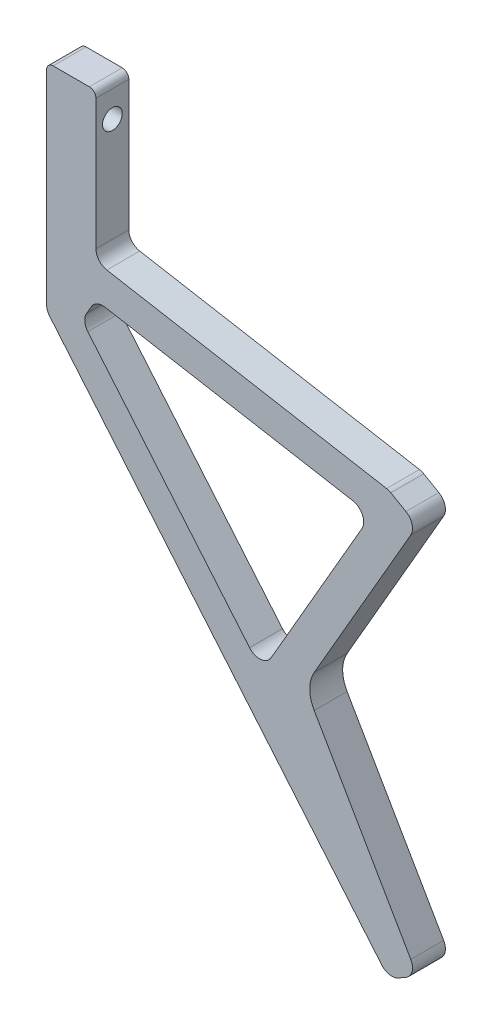
from build123d import *

# Parameters (mm, degrees)
BOSS_EXTRUDE1_DEPTH = 3.175
SKETCH2_R           = 1.905
CUT_EXTRUDE1_DEPTH  = 9.525
CUT_EXTRUDE2_DEPTH  = 6.35
FILLET1_R           = 2.54
FILLET2_R           = 1.27


with BuildPart() as part:
    # Sketch1 → Boss-Extrude1 (new body, symmetric)
    with BuildSketch(Plane.XY):
        with BuildLine():
            Line((-5.499261314, 3.175), (14.408622788, 37.656466735))
            Line((14.408622788, 37.656466735), (8.909361473, 40.831466735))
            Line((8.909361473, 40.831466735), (-47.625, 50.8))
            Line((-47.625, 50.8), (-47.625, 79.375))
            Line((-47.625, 79.375), (-57.15, 79.375))
            Line((-57.15, 79.375), (-57.15, 37.895014625))
            Line((-57.15, 37.895014625), (8.909361473, -40.831466735))
            Line((8.909361473, -40.831466735), (14.408622788, -37.656466735))
            Line((14.408622788, -37.656466735), (-5.499261314, -3.175))
            ThreePointArc((-5.499261314, -3.175), (-6.35, 0), (-5.499261314, 3.175))
        make_face()
    extrude(amount=BOSS_EXTRUDE1_DEPTH, both=True)

    # Sketch2 → Cut-Extrude1 (cut)
    with BuildSketch(Plane(origin=(-47.625, 0, 0), x_dir=(0, 0, -1), z_dir=(1, 0, 0))):
        with Locations((0, 73.025)):
            Circle(SKETCH2_R)
    extrude(amount=-CUT_EXTRUDE1_DEPTH, mode=Mode.SUBTRACT)

    # Sketch3 → Cut-Extrude2 (cut)
    with BuildSketch(Plane.XY.offset(3.175)):
        Polygon((-47.625, 44.352041015), (-50.337094235, 39.654556005), (-15.642242309, -1.693158423), (5.530597046, 34.97927508), align=None)
    extrude(amount=-CUT_EXTRUDE2_DEPTH, mode=Mode.SUBTRACT)

    # Fillet1
    fillet1_edges = [part.edges().sort_by_distance(p)[0] for p in [
        (-47.625, 50.8, 0),
        (8.909361473, 40.831466735, 0),
        (14.408622788, 37.656466735, 0),
        (14.408622788, -37.656466735, 0),
        (8.909361473, -40.831466735, 0),
        (-57.15, 37.895014625, 0),
        (-47.625, 44.352041015, 0),
        (5.530597046, 34.97927508, 0),
        (-15.642242309, -1.693158423, 0),
        (-50.337094235, 39.654556005, 0),
    ]]
    fillet(fillet1_edges, radius=FILLET1_R)

    # Fillet2
    fillet2_edges = [part.edges().sort_by_distance(p)[0] for p in [
        (-57.15, 79.375, 0),
        (-47.625, 79.375, 0),
    ]]
    fillet(fillet2_edges, radius=FILLET2_R)


solid = part.part
